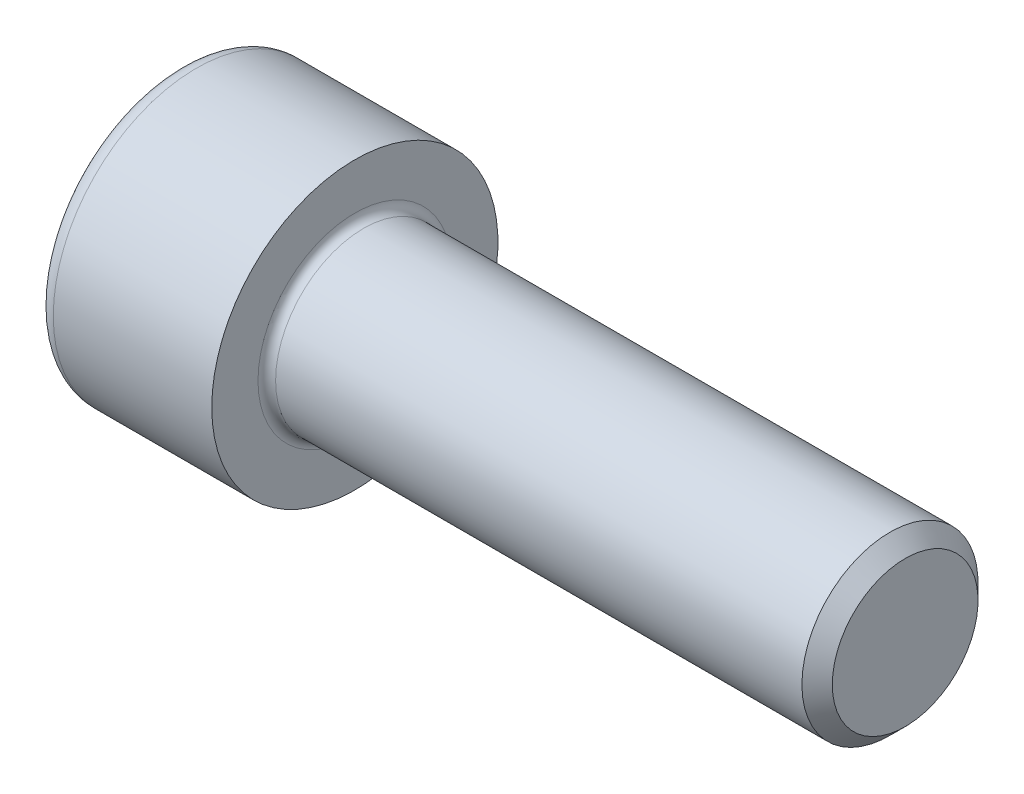
from build123d import *

# Parameters (mm, degrees)
FILLET1_R   = 0.4
FILLET2_R   = 0.8
HEX_2_DEPTH = 4


with BuildPart() as part:
    # BodySke → Base-Revolve (revolve)
    with BuildSketch(Plane.XY, mode=Mode.PRIVATE) as base_revolve_sk:
        Polygon((0, 0), (0, 6.5), (8, 6.5), (8, 4), (32.3095, 4), (33, 3.3095), (33, 0), align=None)
    revolve(base_revolve_sk.sketch.rotate(Axis((-31.75, 0, 0), (1, 0, 0)), 90), axis=Axis((-31.75, 0, 0), (1, 0, 0)))  # turned: the seam where the file's is

    # Fillet1
    fillet1_edges = [part.edges().sort_by_distance(p)[0] for p in [
        (8, 0, -4),
    ]]
    fillet(fillet1_edges, radius=FILLET1_R)

    # Fillet2
    fillet2_edges = [part.edges().sort_by_distance(p)[0] for p in [
        (0, 0, -6.5),
    ]]
    fillet(fillet2_edges, radius=FILLET2_R)

    # Sketch2 → Hex-PreBroach (revolve, cut)
    with BuildSketch(Plane.XY, mode=Mode.PRIVATE) as hex_prebroach_sk:
        Polygon((0, 3.01), (4, 3.01), (5.73782431, 0), (0, 0), align=None)
    revolve(hex_prebroach_sk.sketch.rotate(Axis((0, 0, 0), (1, 0, 0)), 90), axis=Axis((0, 0, 0), (1, 0, 0)), mode=Mode.SUBTRACT)  # turned: the seam where the file's is

    # Sketch3 → Hex 2 (cut)
    with BuildSketch(Plane(origin=(0, 0, 0), x_dir=(0, 0.5, 0.866025404), z_dir=(-1, 0, 0))):
        Polygon((1.73782431, 3.01), (-1.73782431, 3.01), (-3.475648621, 0), (-1.73782431, -3.01), (1.73782431, -3.01), (3.475648621, 0), align=None)
    extrude(amount=-HEX_2_DEPTH, mode=Mode.SUBTRACT)


solid = part.part
